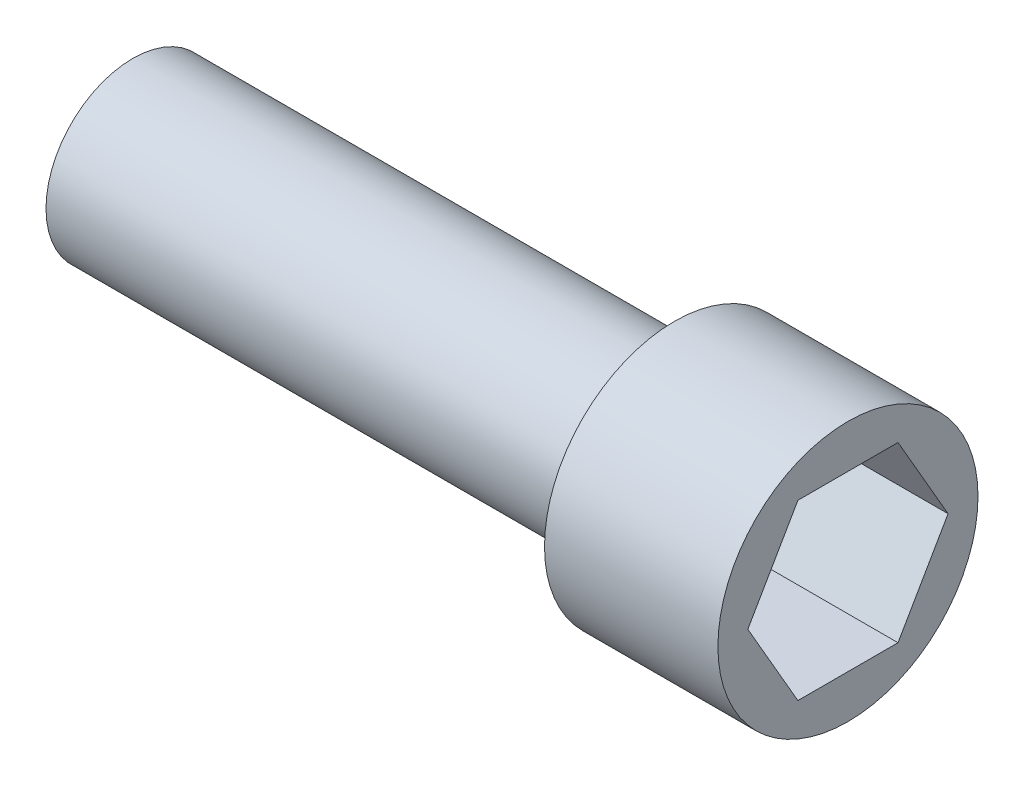
from build123d import *

# Parameters (mm, degrees)
CUT_EXTRUDE1_DEPTH = 6


with BuildPart() as part:
    # Sketch1 → Revolve1 (revolve)
    with BuildSketch(Plane.XY):
        Polygon((16.5, 0), (-16.5, 0), (-16.5, 4), (8.5, 4), (8.5, 6), (16.5, 6), align=None)
    revolve(axis=Axis((16.5, 0, 0), (-1, 0, 0)))

    # Sketch2 → Cut-Extrude1 (cut)
    with BuildSketch(Plane(origin=(16.5, 0, 0), x_dir=(0, 0, -1), z_dir=(1, 0, 0))):
        Polygon((4.618802154, 0), (2.309401077, 4), (-2.309401077, 4), (-4.618802154, 0), (-2.309401077, -4), (2.309401077, -4), align=None)
    extrude(amount=-CUT_EXTRUDE1_DEPTH, mode=Mode.SUBTRACT)


solid = part.part
